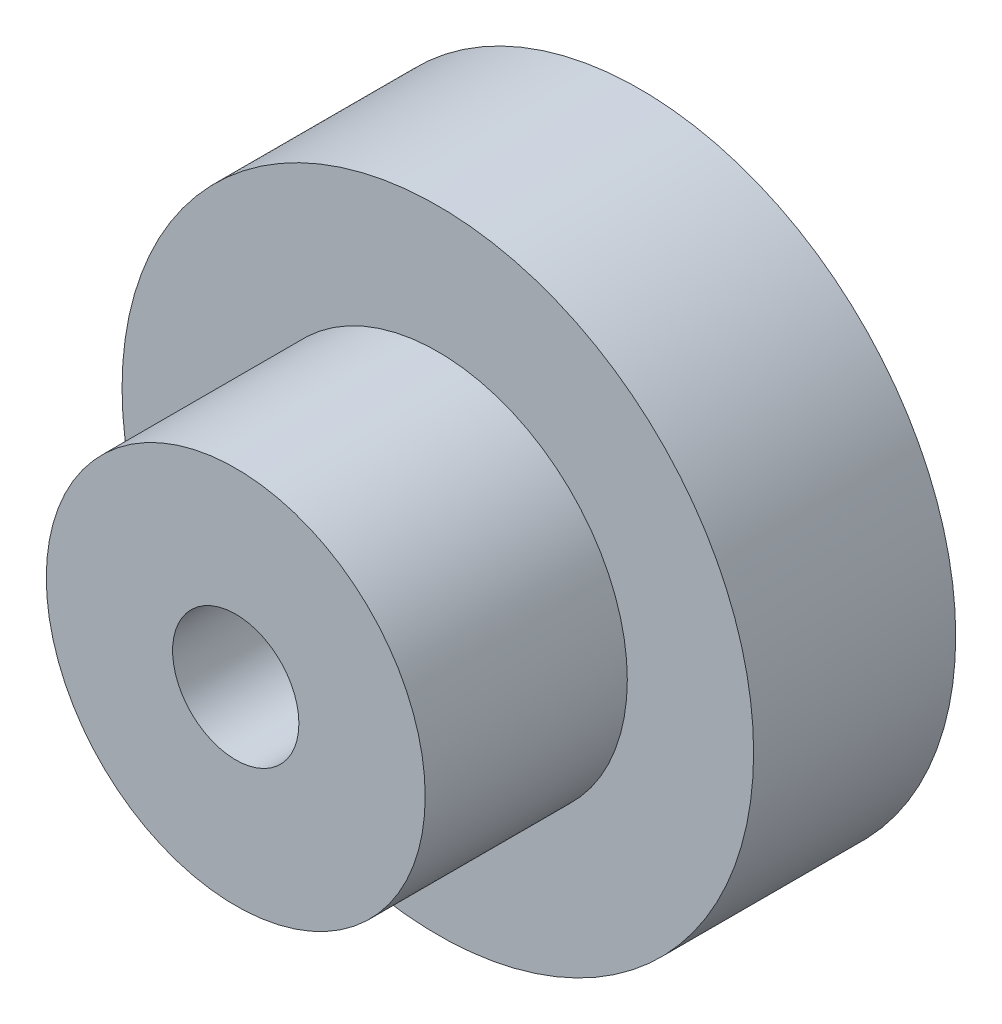
from build123d import *

# Parameters (mm, degrees)
SKETCH_1_R          = 12.5
SKETCH_1_R_2        = 2.5
EXTRUDE_1_DEPTH     = 8
SKETCH_2_R          = 7.5
SKETCH_2_R_2        = 2.5
EXTRUDE_2_DEPTH     = 8
SKETCH_4_R          = 1.5
CUT_EXTRUDE_1_DEPTH = 10


with BuildPart() as part:
    # Эскиз1 → Бобышка-Вытянуть1 (new body)
    with BuildSketch(Plane.XY):
        Circle(SKETCH_1_R)
        Circle(SKETCH_1_R_2, mode=Mode.SUBTRACT)
    extrude(amount=EXTRUDE_1_DEPTH)

    # Эскиз2 → Бобышка-Вытянуть2 (add)
    with BuildSketch(Plane.XY.offset(8)):
        Circle(SKETCH_2_R)
        Circle(SKETCH_2_R_2, mode=Mode.SUBTRACT)
    extrude(amount=EXTRUDE_2_DEPTH)

    # Эскиз4 → Вырез-Вытянуть1 (cut)
    with BuildSketch(Plane(origin=(0, 0, 0), x_dir=(0, 0, -1), z_dir=(1, 0, 0))):
        with Locations((-11, 0)):
            Circle(SKETCH_4_R)
    extrude(amount=-CUT_EXTRUDE_1_DEPTH, mode=Mode.SUBTRACT)


solid = part.part
